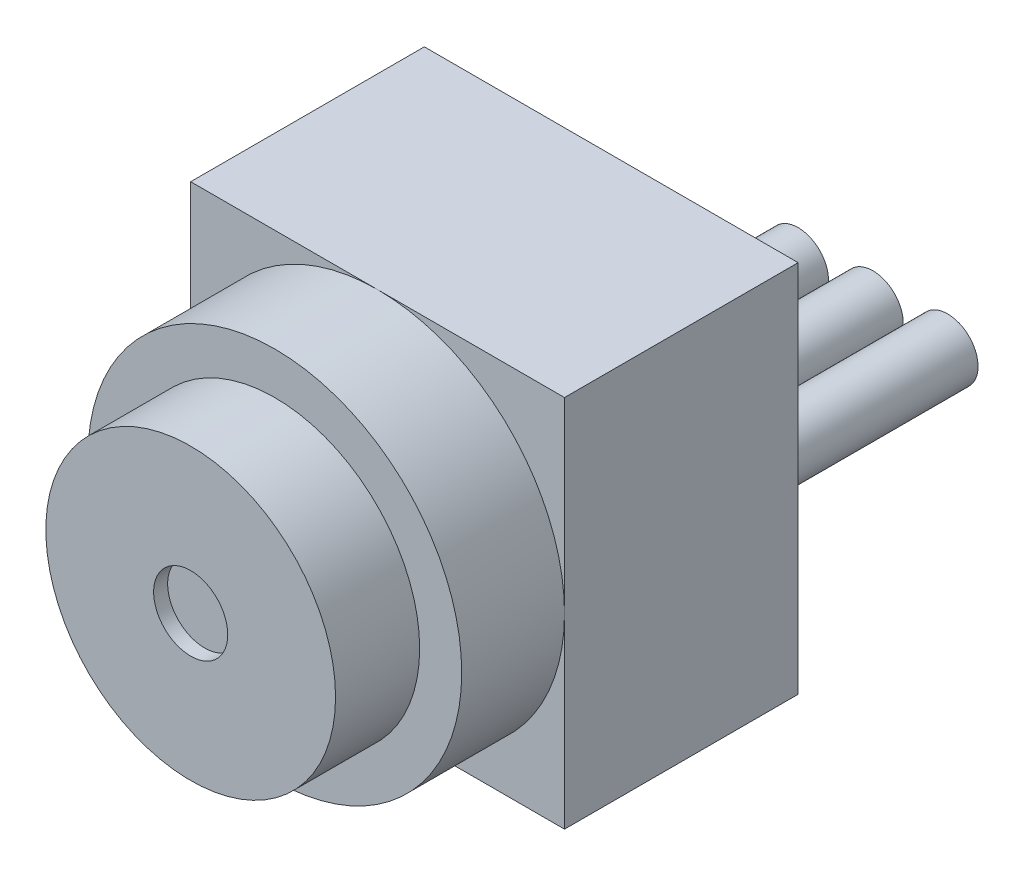
from build123d import *

# Parameters (mm, degrees)
SKETCH1_W      = 10.16
SKETCH1_H      = 10.16
EXTRUDE1_DEPTH = 6.35
SKETCH2_R      = 5.08
EXTRUDE2_DEPTH = 2.794
SKETCH3_R      = 3.937
EXTRUDE3_DEPTH = 2.286
SKETCH4_R      = 1.007103889
EXTRUDE4_DEPTH = 0.381
SKETCH5_R      = 0.8255
EXTRUDE5_DEPTH = 5.08


with BuildPart() as part:
    # Sketch1 → Extrude1 (new body)
    with BuildSketch(Plane.XY):
        with Locations((5.08, 5.08)):
            Rectangle(SKETCH1_W, SKETCH1_H)
    extrude(amount=EXTRUDE1_DEPTH)

    # Sketch2 → Extrude2 (add)
    with BuildSketch(Plane.XY.offset(6.35)):
        with Locations((5.08, 5.08)):
            Circle(SKETCH2_R)
    extrude(amount=EXTRUDE2_DEPTH)

    # Sketch3 → Extrude3 (add)
    with BuildSketch(Plane.XY.offset(9.144)):
        with Locations((5.08, 5.08)):
            Circle(SKETCH3_R)
    extrude(amount=EXTRUDE3_DEPTH)

    # Sketch4 → Extrude4 (cut)
    with BuildSketch(Plane.XY.offset(11.43)):
        with Locations((5.08, 5.08)):
            Circle(SKETCH4_R)
    extrude(amount=-EXTRUDE4_DEPTH, mode=Mode.SUBTRACT)

    # Sketch5 → Extrude5 (add)
    with BuildSketch(Plane(origin=(0, 0, 0), x_dir=(-1, 0, 0), z_dir=(0, 0, -1))):
        with Locations((-5.08, 5.08)):
            Circle(SKETCH5_R)
        with Locations((-7.112, 5.08)):
            Circle(SKETCH5_R)
        with Locations((-9.144, 5.08)):
            Circle(SKETCH5_R)
    extrude(amount=EXTRUDE5_DEPTH)


solid = part.part
